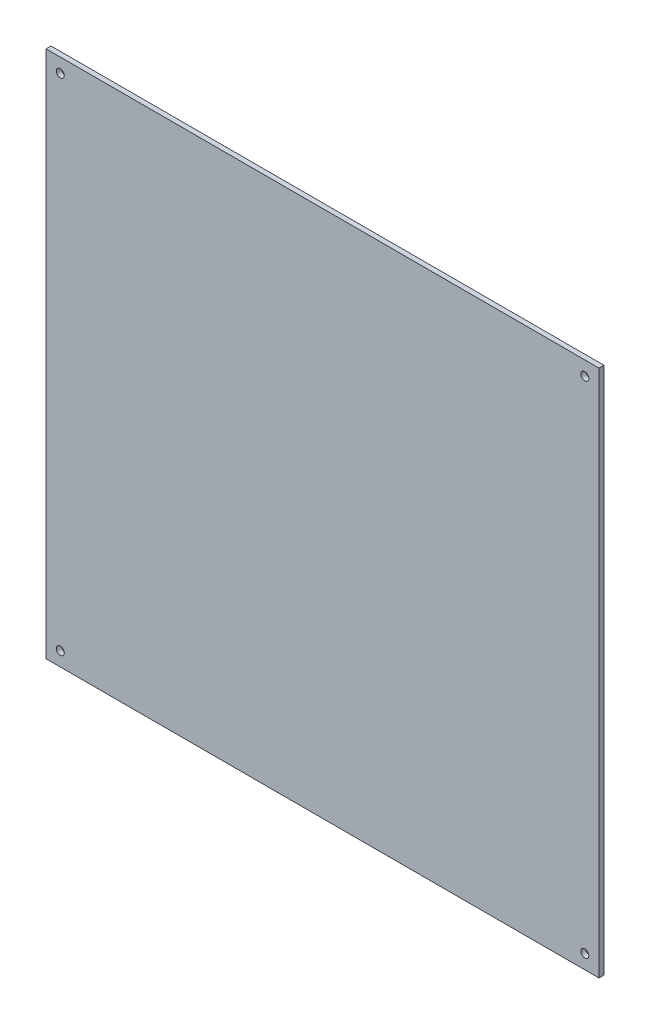
from build123d import *

# Parameters (mm, degrees)
SCHIZZO1_W                   = 449
SCHIZZO1_H                   = 429
SCHIZZO1_R                   = 3.25
ESTRUSIONE_ESTRUSIONE1_DEPTH = 4


with BuildPart() as part:
    # Schizzo1 → Estrusione-Estrusione1 (new body)
    with BuildSketch(Plane.XY):
        with Locations((-224.5, 214.5)):
            Rectangle(SCHIZZO1_W, SCHIZZO1_H)
        with Locations((-437.5, 417.5)):
            Circle(SCHIZZO1_R, mode=Mode.SUBTRACT)
        with Locations((-11.5, 417.5)):
            Circle(SCHIZZO1_R, mode=Mode.SUBTRACT)
        with Locations((-437.5, 11.5)):
            Circle(SCHIZZO1_R, mode=Mode.SUBTRACT)
        with Locations((-11.5, 11.5)):
            Circle(SCHIZZO1_R, mode=Mode.SUBTRACT)
    extrude(amount=ESTRUSIONE_ESTRUSIONE1_DEPTH)


solid = part.part
